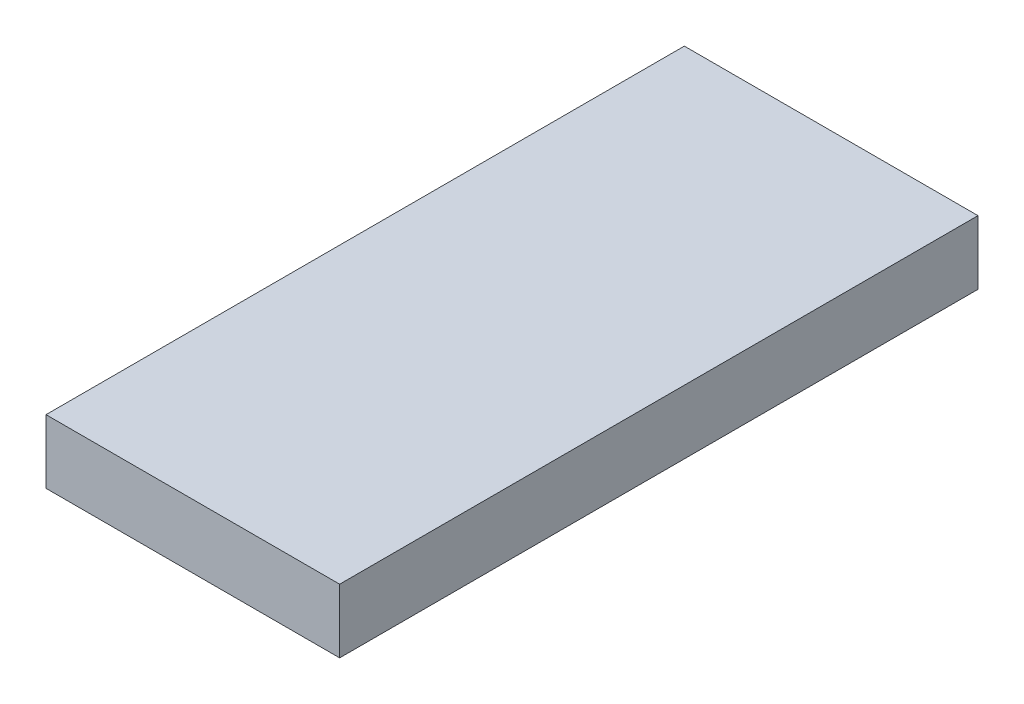
from build123d import *

# Parameters (mm, degrees)
SKETCH1_W           = 36.5125
SKETCH1_H           = 79.375
BOSS_EXTRUDE1_DEPTH = 7.9375


with BuildPart() as part:
    # Sketch1 → Boss-Extrude1 (new body)
    with BuildSketch(Plane(origin=(0, 0, 0), x_dir=(1, 0, 0), z_dir=(0, 1, 0))):
        with Locations((18.25625, 39.6875)):
            Rectangle(SKETCH1_W, SKETCH1_H)
    extrude(amount=BOSS_EXTRUDE1_DEPTH)


solid = part.part
